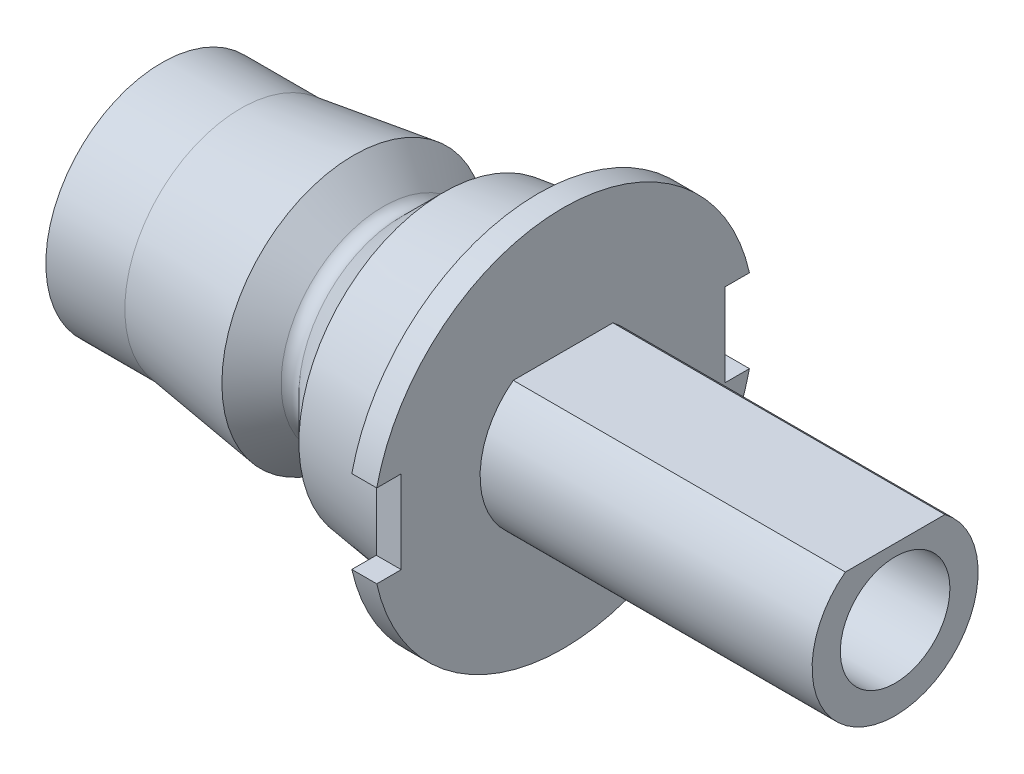
from build123d import *

# Parameters (mm, degrees)
SKETCH3_W           = 2
SKETCH3_H           = 5
CUT_EXTRUDE6_DEPTH  = 25.176500961
BOSS_EXTRUDE4_DEPTH = 20
SKETCH2_R           = 3.3
CUT_EXTRUDE7_DEPTH  = 45.176500961


with BuildPart() as part:
    # Sketch1 → Revolve3 (revolve)
    with BuildSketch(Plane.XY):
        with BuildLine():
            Line((0, 0), (0, 6.982))
            Line((0, 6.982), (4.76, 6.982))
            Line((4.76, 6.982), (11.56, 7.937677676))
            Line((11.56, 7.937677676), (13.343138593, 6.154539083))
            ThreePointArc((13.343138593, 6.154539083), (13.880539746, 5.931940237), (14.4179409, 6.154539083))
            Line((14.4179409, 6.154539083), (16.96, 8.696598183))
            Line((16.96, 8.696598183), (22.676500961, 9.5))
            Line((22.676500961, 9.5), (22.676500961, 11.5))
            Line((22.676500961, 11.5), (24.176500961, 11.5))
            Line((24.176500961, 11.5), (24.176500961, 0))
            Line((24.176500961, 0), (0, 0))
        make_face()
    revolve(axis=Axis((24.176500961, 0, 0), (-1, 0, 0)))

    # Sketch3 → Cut-Extrude6 (cut, through all)
    with BuildSketch(Plane(origin=(24.176500961, 0, 0), x_dir=(0, 0, -1), z_dir=(1, 0, 0))):
        with Locations((-10.75, 0)):
            Rectangle(SKETCH3_W, SKETCH3_H)
        with Locations((10.75, 0)):
            Rectangle(SKETCH3_W, SKETCH3_H)
    extrude(amount=-CUT_EXTRUDE6_DEPTH, mode=Mode.SUBTRACT)

    # Sketch4 → Boss-Extrude4 (add)
    with BuildSketch(Plane(origin=(24.176500961, 0, 0), x_dir=(0, 0, -1), z_dir=(1, 0, 0))):
        with BuildLine():
            Line((-3, 4), (3, 4))
            ThreePointArc((3, 4), (0, -5), (-3, 4))
        make_face()
    extrude(amount=BOSS_EXTRUDE4_DEPTH)

    # Sketch2 → Cut-Extrude7 (cut, through all)
    with BuildSketch(Plane(origin=(0, 0, 0), x_dir=(0, 0, -1), z_dir=(1, 0, 0))):
        Circle(SKETCH2_R)
    extrude(amount=CUT_EXTRUDE7_DEPTH, mode=Mode.SUBTRACT)


solid = part.part
